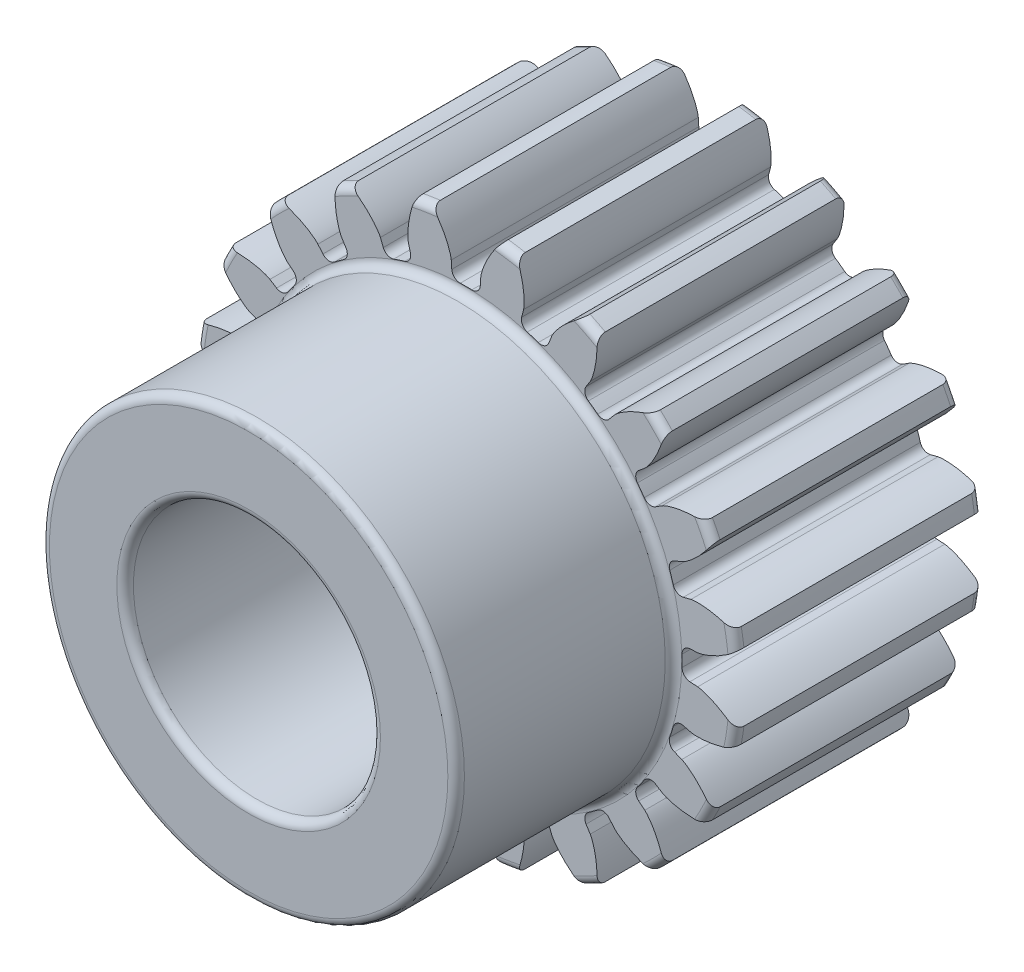
from build123d import *

# Parameters (mm, degrees)
SKETCH3_R                = 13.97
BOSS_EXTRUDE1_DEPTH      = 11.938
BOSS_EXTRUDE1_DEPTH_BACK = 11.938
SKETCH5_W                = 11.176
SKETCH5_H                = 3.302
SKETCH5_W_2              = 23.876
SKETCH5_H_2              = 6.35
FILLET2_R                = 0.426091396
CUT_EXTRUDE1_START       = -12.9380001
CUT_EXTRUDE1_DEPTH       = 25.8760001
FILLET1_R                = 0.426091396
CIRPATTERN1_COUNT        = 20
FILLET1_OF_CIRPATTERN1_R = 0.426091396


with BuildPart() as part:
    # Sketch3 → Boss-Extrude1 (new body, two sides)
    with BuildSketch(Plane.XY) as boss_extrude1_sk:
        Circle(SKETCH3_R)
    extrude(amount=BOSS_EXTRUDE1_DEPTH)
    extrude(boss_extrude1_sk.sketch, amount=-BOSS_EXTRUDE1_DEPTH_BACK)

    # Sketch5 → Cut-Revolve1 (revolve, cut)
    with BuildSketch(Plane(origin=(0, 0, 0), x_dir=(0, 0, -1), z_dir=(1, 0, 0))):
        with Locations((-6.35, 12.319)):
            Rectangle(SKETCH5_W, SKETCH5_H)
        with Locations((0, 3.175)):
            Rectangle(SKETCH5_W_2, SKETCH5_H_2)
    revolve(axis=Axis((0, 0, 11.938), (0, 0, -1)), mode=Mode.SUBTRACT)

    # Fillet2
    fillet2_edges = [part.edges().sort_by_distance(p)[0] for p in [
        (0, -6.35, 11.938),
        (0, -6.35, -11.938),
        (0, -10.668, 11.938),
        (0, -10.668, 0.762),
        (-13.97, 0, 0.762),
        (-13.97, 0, -11.938),
    ]]
    fillet(fillet2_edges, radius=FILLET2_R)

    # Sketch4 → Cut-Extrude1 (cut)
    with BuildSketch(Plane.XY.offset(CUT_EXTRUDE1_START)):
        with BuildLine():
            Line((11.090007734, 0.706671577), (11.909941065, 0.758918933))
            add(Edge.make_bspline(
                [(11.909941065, 0.758918933), (11.91319885, 0.75916867), (11.922326373, 0.759999028), (11.939541821, 0.762081733), (11.967563, 0.766207532), (12.003153475, 0.772532437), (12.049006316, 0.78193155), (12.102812796, 0.794575497), (12.161703212, 0.81011376), (12.2254893, 0.828787319), (12.288855455, 0.848977261), (12.351797854, 0.870566157), (12.414244834, 0.89337607), (12.489569754, 0.922542307), (12.579436809, 0.959648005), (12.683765988, 1.006111611), (12.80121371, 1.062447697), (12.919908456, 1.123732073), (13.035856633, 1.187207606), (13.151968715, 1.254962387), (13.263573377, 1.323083241), (13.378357846, 1.397516484), (13.483735575, 1.468094979), (13.600466468, 1.551203565), (13.694286594, 1.619454211), (13.790047056, 1.693297947), (13.836481646, 1.72972993), (13.860139004, 1.748555626)],
                knots=[0, 0, 0, 0, 0, 0.005376749, 0.015083688, 0.02853182, 0.04661014, 0.064854849, 0.092110526, 0.119476176, 0.146842496, 0.174208854, 0.201574956, 0.228941013, 0.256307345, 0.307035032, 0.361767352, 0.416499661, 0.471231937, 0.525964282, 0.580696616, 0.635428982, 0.690161387, 0.744893688, 0.799626082, 0.854358407, 0.909090915, 0.909090915, 0.909090915, 0.909090915, 0.909090915], degree=4))
            ThreePointArc((13.860139004, 1.748555626), (13.97, 0), (13.860139004, -1.748555626))
            add(Edge.make_bspline(
                [(11.909941065, -0.758918933), (11.91319885, -0.75916867), (11.922326373, -0.759999028), (11.939541821, -0.762081733), (11.967563, -0.766207532), (12.003153475, -0.772532437), (12.049006316, -0.78193155), (12.102812796, -0.794575497), (12.161703212, -0.81011376), (12.2254893, -0.828787319), (12.288855455, -0.848977261), (12.351797854, -0.870566157), (12.414244834, -0.89337607), (12.489569754, -0.922542307), (12.579436809, -0.959648005), (12.683765988, -1.006111611), (12.80121371, -1.062447697), (12.919908456, -1.123732073), (13.035856633, -1.187207606), (13.151968715, -1.254962387), (13.263573377, -1.323083241), (13.378357846, -1.397516484), (13.483735575, -1.468094979), (13.600466468, -1.551203565), (13.694286594, -1.619454211), (13.790047056, -1.693297947), (13.836481646, -1.72972993), (13.860139004, -1.748555626)],
                knots=[0, 0, 0, 0, 0, 0.005376749, 0.015083688, 0.02853182, 0.04661014, 0.064854849, 0.092110526, 0.119476176, 0.146842496, 0.174208854, 0.201574956, 0.228941013, 0.256307345, 0.307035032, 0.361767352, 0.416499661, 0.471231937, 0.525964282, 0.580696616, 0.635428982, 0.690161387, 0.744893688, 0.799626082, 0.854358407, 0.909090915, 0.909090915, 0.909090915, 0.909090915, 0.909090915], degree=4))
            Line((11.909941065, -0.758918933), (11.090007734, -0.706671577))
            ThreePointArc((11.090007734, -0.706671577), (11.1125, 0), (11.090007734, 0.706671577))
        make_face()
    cut_extrude1 = extrude(amount=CUT_EXTRUDE1_DEPTH, mode=Mode.SUBTRACT)

    # Fillet1
    fillet1_edges = [part.edges().sort_by_distance(p)[0] for p in [
        (11.090007734, -0.706671577, -5.588),
        (11.090007734, 0.706671577, -5.588),
    ]]
    fillet(fillet1_edges, radius=FILLET1_R)

    # CirPattern1: Cut-Extrude1 ×20 about axis
    cirpattern1_axis = Axis((0, 0, 11.938), (0, 0, -1))
    for i in range(1, CIRPATTERN1_COUNT):
        add(cut_extrude1.rotate(cirpattern1_axis, i * 360 / CIRPATTERN1_COUNT), mode=Mode.SUBTRACT)

    # Fillet1 of CirPattern1
    fillet1_of_cirpattern1_edges = [part.edges().sort_by_distance(p)[0] for p in [
        (10.328850594, -4.099085466, -5.588),
        (10.765597648, -2.754916249, -5.588),
        (8.556633593, -7.090252309, -5.588),
        (9.387375856, -5.946833678, -5.588),
        (5.946833678, -9.387375856, -5.588),
        (7.090252309, -8.556633593, -5.588),
        (2.754916249, -10.765597648, -5.588),
        (4.099085466, -10.328850594, -5.588),
        (-0.706671577, -11.090007734, -5.588),
        (0.706671577, -11.090007734, -5.588),
        (-4.099085466, -10.328850594, -5.588),
        (-2.754916249, -10.765597648, -5.588),
        (-7.090252309, -8.556633593, -5.588),
        (-5.946833678, -9.387375856, -5.588),
        (-9.387375856, -5.946833678, -5.588),
        (-8.556633593, -7.090252309, -5.588),
        (-10.765597648, -2.754916249, -5.588),
        (-10.328850594, -4.099085466, -5.588),
        (-11.090007734, 0.706671577, -5.588),
        (-11.090007734, -0.706671577, -5.588),
        (-10.328850594, 4.099085466, -5.588),
        (-10.765597648, 2.754916249, -5.588),
        (-8.556633593, 7.090252309, -5.588),
        (-9.387375856, 5.946833678, -5.588),
        (-5.946833678, 9.387375856, -5.588),
        (-7.090252309, 8.556633593, -5.588),
        (-2.754916249, 10.765597648, -5.588),
        (-4.099085466, 10.328850594, -5.588),
        (0.706671577, 11.090007734, -5.588),
        (-0.706671577, 11.090007734, -5.588),
        (4.099085466, 10.328850594, -5.588),
        (2.754916249, 10.765597648, -5.588),
        (7.090252309, 8.556633593, -5.588),
        (5.946833678, 9.387375856, -5.588),
        (9.387375856, 5.946833678, -5.588),
        (8.556633593, 7.090252309, -5.588),
        (10.765597648, 2.754916249, -5.588),
        (10.328850594, 4.099085466, -5.588),
    ]]
    fillet(fillet1_of_cirpattern1_edges, radius=FILLET1_OF_CIRPATTERN1_R)


solid = part.part
